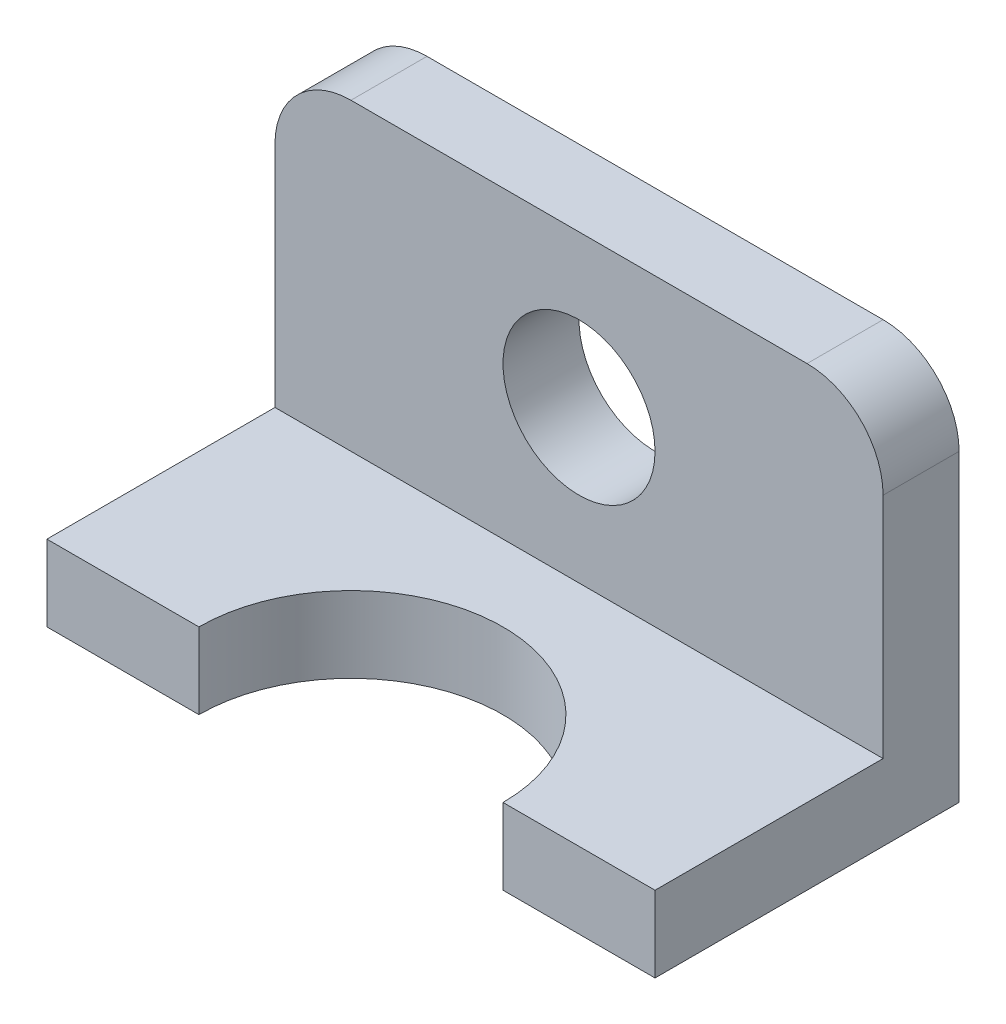
from build123d import *

# Parameters (mm, degrees)
BOSS_EXTRUDE1_DEPTH = 12.7
SKETCH2_W           = 101.6
SKETCH2_H           = 12.7
BOSS_EXTRUDE2_DEPTH = 50.8
SKETCH3_R           = 12.7
CUT_EXTRUDE1_DEPTH  = 13.7
FILLET2_R           = 12.7


with BuildPart() as part:
    # Sketch1 → Boss-Extrude1 (new body)
    with BuildSketch(Plane(origin=(0, 0, 0), x_dir=(1, 0, 0), z_dir=(0, 1, 0))):
        with BuildLine():
            Line((-50.8, -50.8), (-50.8, 0))
            Line((-50.8, 0), (50.8, 0))
            Line((50.8, 0), (50.8, -50.8))
            Line((50.8, -50.8), (25.4, -50.8))
            ThreePointArc((25.4, -50.8), (0, -25.4), (-25.4, -50.8))
            Line((-25.4, -50.8), (-50.8, -50.8))
        make_face()
    extrude(amount=BOSS_EXTRUDE1_DEPTH)

    # Sketch2 → Boss-Extrude2 (add)
    with BuildSketch(Plane(origin=(0, 12.7, 0), x_dir=(1, 0, 0), z_dir=(0, 1, 0))):
        with Locations((0, -6.35)):
            Rectangle(SKETCH2_W, SKETCH2_H)
    extrude(amount=BOSS_EXTRUDE2_DEPTH)

    # Sketch3 → Cut-Extrude1 (cut, through all)
    with BuildSketch(Plane.XY.offset(12.7)):
        with Locations((0, 38.1)):
            Circle(SKETCH3_R)
    extrude(amount=-CUT_EXTRUDE1_DEPTH, mode=Mode.SUBTRACT)

    # Fillet2
    fillet2_edges = [part.edges().sort_by_distance(p)[0] for p in [
        (-50.8, 63.5, 6.35),
        (50.8, 63.5, 6.35),
    ]]
    fillet(fillet2_edges, radius=FILLET2_R)


solid = part.part
